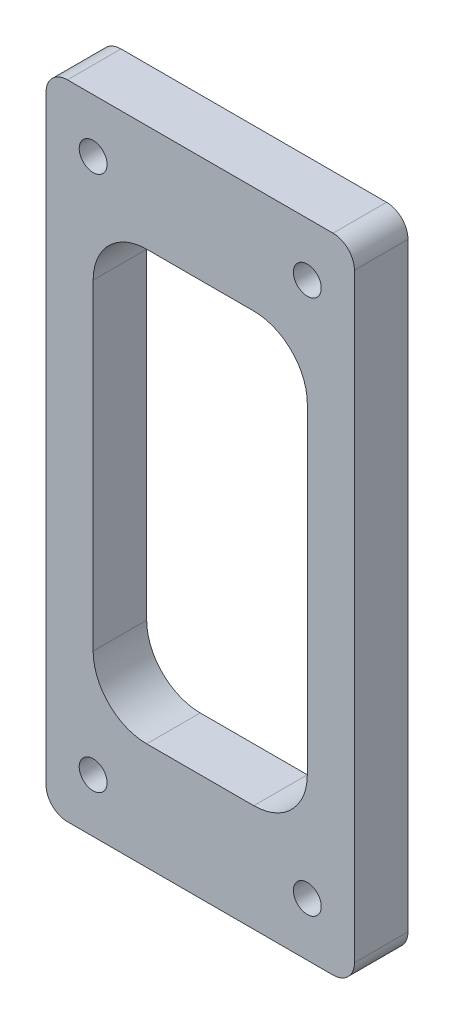
from build123d import *

# Parameters (mm, degrees)
SZKIC1_W                    = 28.8
SZKIC1_H                    = 60
DODANIE_WYCI_GNI_CIE1_DEPTH = 5
ZAOKR_GLENIE1_R             = 2
OTW_R_POD_RUB_M22_D         = 2.6
WYTNIJ_WYCI_GNI_CIE1_REACH  = 7


with BuildPart() as part:
    # Szkic1 → Dodanie-wyciągnięcie1 (new body)
    with BuildSketch(Plane.XY):
        Rectangle(SZKIC1_W, SZKIC1_H)
    extrude(amount=DODANIE_WYCI_GNI_CIE1_DEPTH)

    # Zaokrąglenie1
    zaokr_glenie1_edges = [part.edges().sort_by_distance(p)[0] for p in [
        (14.4, -30, 2.5),
        (-14.4, -30, 2.5),
        (-14.4, 30, 2.5),
        (14.4, 30, 2.5),
    ]]
    fillet(zaokr_glenie1_edges, radius=ZAOKR_GLENIE1_R)

    # Otwór pod śrubę M22 (through all)
    with Locations(Plane.XY.offset(5)):
        with Locations((10, 25), (10, -25), (-10, -25), (-10, 25)):
            Hole(OTW_R_POD_RUB_M22_D / 2)

    # Szkic7 → Wytnij-wyciągnięcie1 (cut, up to next)
    with BuildSketch(Plane.XY.offset(5), mode=Mode.PRIVATE) as wytnij_wyci_gni_cie1_sk1:
        with BuildLine():
            Line((5, 20), (-5, 20))
            ThreePointArc((-5, 20), (-8.535533906, 18.535533906), (-10, 15))
            Line((-10, 15), (-10, -15))
            ThreePointArc((-10, -15), (-8.535533906, -18.535533906), (-5, -20))
            Line((-5, -20), (5, -20))
            ThreePointArc((5, -20), (8.535533906, -18.535533906), (10, -15))
            Line((10, -15), (10, 15))
            ThreePointArc((10, 15), (8.535533906, 18.535533906), (5, 20))
        make_face()
    wytnij_wyci_gni_cie1_tool1 = extrude(wytnij_wyci_gni_cie1_sk1.sketch, amount=-WYTNIJ_WYCI_GNI_CIE1_REACH, mode=Mode.PRIVATE) & part.part
    add(wytnij_wyci_gni_cie1_tool1.solids().sort_by_distance((0, 0, 5))[0], mode=Mode.SUBTRACT)


solid = part.part
